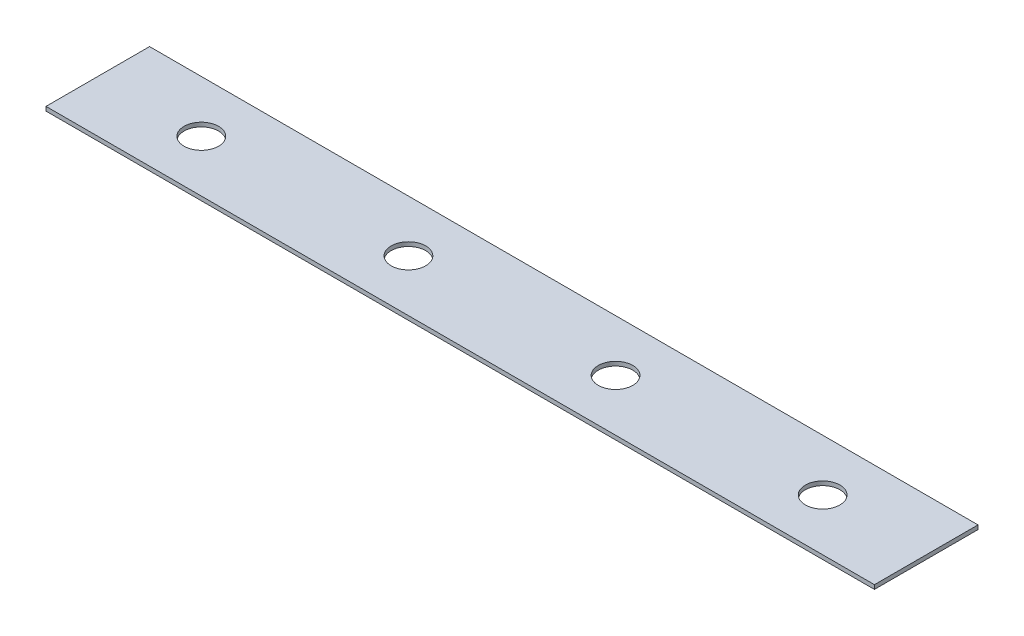
from build123d import *

# Parameters (mm, degrees)
SKETCH1_W           = 38.1
SKETCH1_H           = 1.51892
BOSS_EXTRUDE1_DEPTH = 304.8
SKETCH3_R           = 6.35
CUT_EXTRUDE1_DEPTH  = 2.51892


with BuildPart() as part:
    # Sketch1 → Boss-Extrude1 (new body)
    with BuildSketch(Plane(origin=(0, 0, 0), x_dir=(0, 0, -1), z_dir=(1, 0, 0))):
        with Locations((19.05, 0.75946)):
            Rectangle(SKETCH1_W, SKETCH1_H)
    extrude(amount=BOSS_EXTRUDE1_DEPTH)

    # Sketch3 → Cut-Extrude1 (cut, through all)
    with BuildSketch(Plane(origin=(0, 1.51892, 0), x_dir=(1, 0, 0), z_dir=(0, 1, 0))):
        with Locations((114.3, 19.05)):
            Circle(SKETCH3_R)
        with Locations((190.5, 19.05)):
            Circle(SKETCH3_R)
        with Locations((266.7, 19.05)):
            Circle(SKETCH3_R)
        with Locations((38.1, 19.05)):
            Circle(SKETCH3_R)
    extrude(amount=-CUT_EXTRUDE1_DEPTH, mode=Mode.SUBTRACT)


solid = part.part
